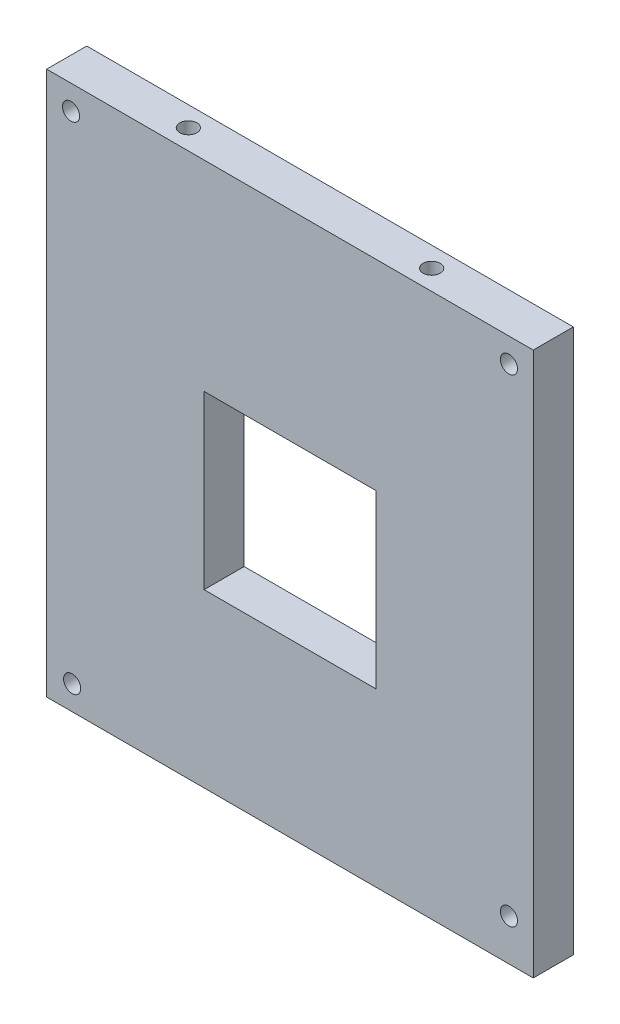
from build123d import *

# Parameters (mm, degrees)
SKETCH1_W           = 85
SKETCH1_H           = 95
BOSS_EXTRUDE1_DEPTH = 7
SKETCH2_W           = 30
SKETCH2_H           = 30
CUT_EXTRUDE1_DEPTH  = 7
SKETCH4_R           = 1.5
CUT_EXTRUDE2_DEPTH  = 5
SKETCH6_R           = 1.5
CUT_EXTRUDE3_DEPTH  = 8


with BuildPart() as part:
    # Sketch1 → Boss-Extrude1 (new body)
    with BuildSketch(Plane.XY):
        with Locations((42.5, 47.5)):
            Rectangle(SKETCH1_W, SKETCH1_H)
    extrude(amount=BOSS_EXTRUDE1_DEPTH)

    # Sketch2 → Cut-Extrude1 (cut)
    with BuildSketch(Plane.XY.offset(7)):
        with Locations((42.5, 45)):
            Rectangle(SKETCH2_W, SKETCH2_H)
    extrude(amount=-CUT_EXTRUDE1_DEPTH, mode=Mode.SUBTRACT)

    # Sketch4 → Cut-Extrude2 (cut)
    with BuildSketch(Plane(origin=(0, 95, 0), x_dir=(1, 0, 0), z_dir=(0, 1, 0))):
        with Locations((21.25, -3.5)):
            Circle(SKETCH4_R)
        with Locations((63.75, -3.5)):
            Circle(SKETCH4_R)
    extrude(amount=-CUT_EXTRUDE2_DEPTH, mode=Mode.SUBTRACT)

    # Sketch6 → Cut-Extrude3 (cut)
    with BuildSketch(Plane(origin=(0, 0, 0), x_dir=(-1, 0, 0), z_dir=(0, 0, -1))):
        with Locations((-80.75, 90.75)):
            Circle(SKETCH6_R)
        with Locations((-4.25, 90.75)):
            Circle(SKETCH6_R)
        with Locations((-4.45, 4.25)):
            Circle(SKETCH6_R)
        with Locations((-80.75, 7.25)):
            Circle(SKETCH6_R)
    extrude(amount=-CUT_EXTRUDE3_DEPTH, mode=Mode.SUBTRACT)


solid = part.part
